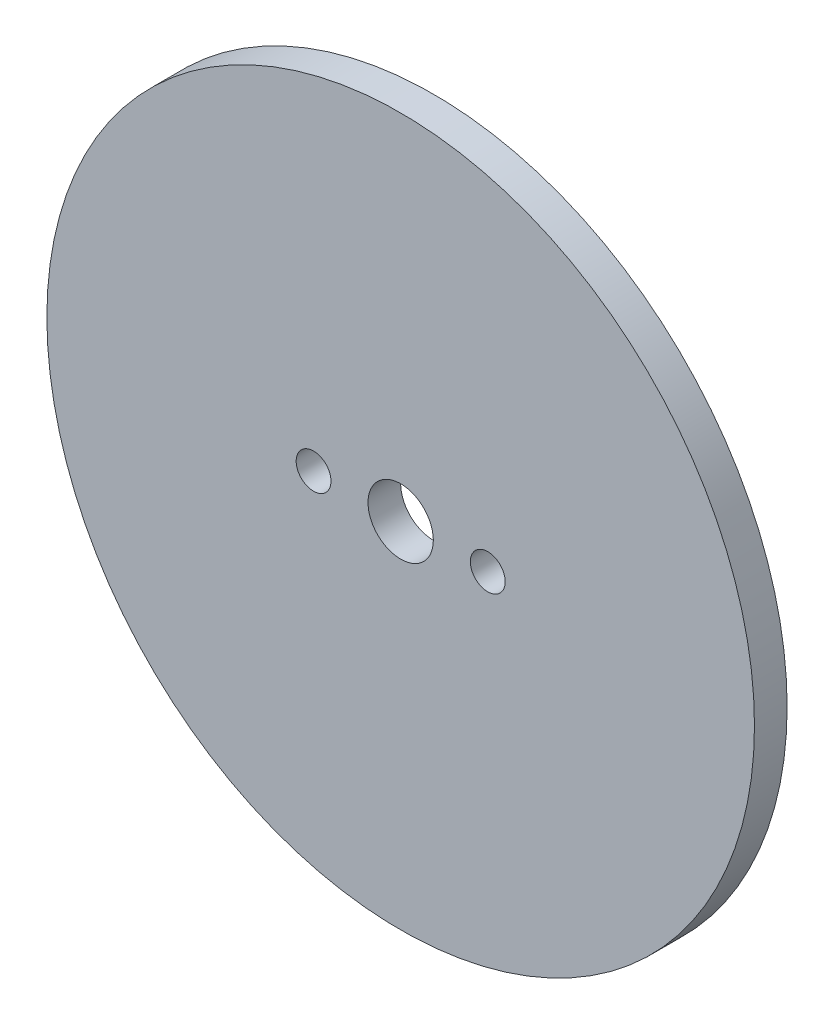
from build123d import *

# Parameters (mm, degrees)
ESBO_O1_R                = 32.5
ESBO_O1_R_2              = 3
ESBO_O1_R_3              = 1.6
RESSALTO_EXTRUS_O1_DEPTH = 3


with BuildPart() as part:
    # Esboço1 → Ressalto-extrusão1 (new body)
    with BuildSketch(Plane.XY):
        Circle(ESBO_O1_R)
        Circle(ESBO_O1_R_2, mode=Mode.SUBTRACT)
        with Locations((8, 0)):
            Circle(ESBO_O1_R_3, mode=Mode.SUBTRACT)
        with Locations((-8, 0)):
            Circle(ESBO_O1_R_3, mode=Mode.SUBTRACT)
    extrude(amount=RESSALTO_EXTRUS_O1_DEPTH)


solid = part.part
